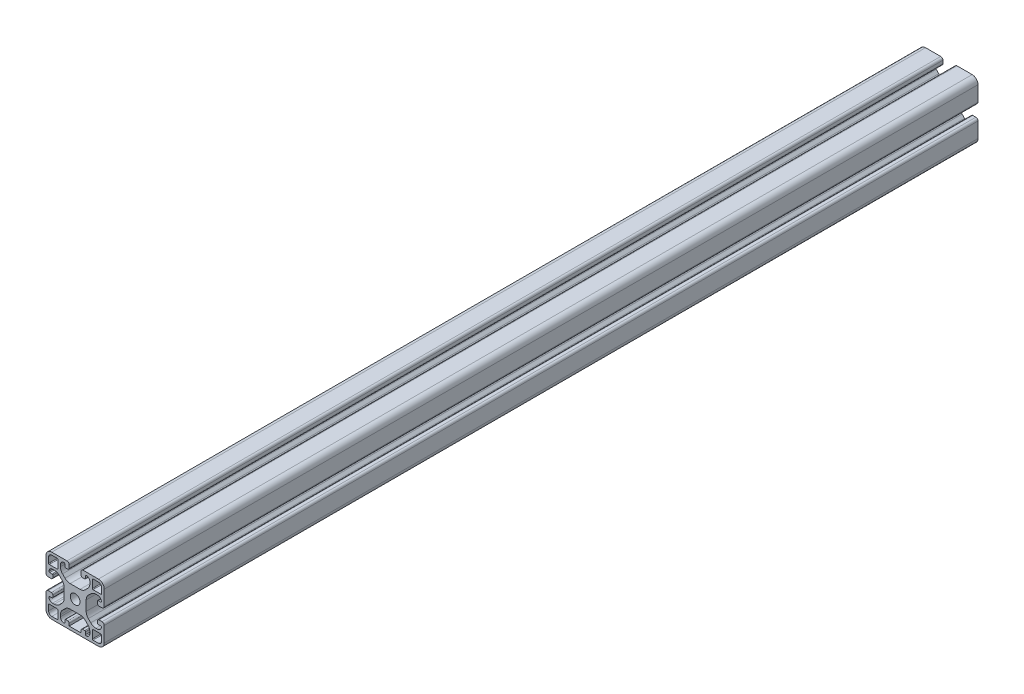
from build123d import *

# Parameters (mm, degrees)
SKIZZE1_R                       = 3.35
AUFSATZ_LINEAR_AUSTRAGEN1_DEPTH = 600


with BuildPart() as part:
    # Skizze1 → Aufsatz-Linear austragen1 (new body)
    with BuildSketch(Plane.XY.offset(1000)):
        with BuildLine():
            Line((5.899999985, 34.292388165), (5.899999985, 35.500000003))
            ThreePointArc((5.899999985, 35.500000003), (6.632233037, 37.267766961), (8.399999999, 38.000000003))
            ThreePointArc((8.399999999, 38.000000003), (8.753553388, 37.853553393), (8.899999996, 37.500000003))
            Line((8.899999996, 37.500000003), (8.899999996, 35.850000004))
            ThreePointArc((8.899999996, 35.850000004), (9.046446605, 35.496446613), (9.399999996, 35.350000004))
            Line((9.399999996, 35.350000004), (10.899999947, 35.350000004))
            ThreePointArc((10.899999947, 35.350000004), (11.607106728, 35.642893223), (11.899999947, 36.350000004))
            Line((11.899999947, 36.350000004), (11.899999947, 38.500000016))
            ThreePointArc((11.899999947, 38.500000016), (11.460660119, 39.560660188), (10.399999947, 40.000000016))
            Line((10.399999947, 40.000000016), (5.2e-08, 40.000000016))
            ThreePointArc((5.2e-08, 40.000000016), (-2.828427117, 38.828427123), (-4.000000011, 35.999999954))
            Line((-4.000000011, 35.999999954), (-4.000000011, 25.599999996))
            ThreePointArc((-4.000000011, 25.599999996), (-3.560660183, 24.539339825), (-2.500000012, 24.099999997))
            Line((-2.500000012, 24.099999997), (-0.350000011, 24.099999997))
            ThreePointArc((-0.350000011, 24.099999997), (0.35710677, 24.392893216), (0.649999989, 25.099999997))
            Line((0.649999989, 25.099999997), (0.649999989, 26.599999997))
            ThreePointArc((0.649999989, 26.599999997), (0.50355338, 26.953553387), (0.149999989, 27.099999997))
            Line((0.149999989, 27.099999997), (-1.500000011, 27.099999997))
            ThreePointArc((-1.500000011, 27.099999997), (-1.853553401, 27.246446605), (-2.000000011, 27.599999993))
            ThreePointArc((-2.000000011, 27.599999993), (-1.26776697, 29.367766957), (0.499999989, 30.10000001))
            Line((0.499999989, 30.10000001), (1.707611833, 30.10000001))
            ThreePointArc((1.707611833, 30.10000001), (3.621028995, 29.719397673), (5.243145739, 28.635533916))
            Line((5.243145739, 28.635533916), (6.935533894, 26.943145761))
            ThreePointArc((6.935533894, 26.943145761), (8.01939765, 25.321029017), (8.399999988, 23.407611855))
            Line((8.399999988, 23.407611855), (8.399999988, 16.592388122))
            ThreePointArc((8.399999988, 16.592388122), (8.01939765, 14.678970961), (6.935533894, 13.056854217))
            Line((6.935533894, 13.056854217), (5.243145737, 11.36446606))
            ThreePointArc((5.243145737, 11.36446606), (3.621028993, 10.280602303), (1.707611831, 9.899999966))
            Line((1.707611831, 9.899999966), (0.49999999, 9.899999966))
            ThreePointArc((0.49999999, 9.899999966), (-1.267766968, 10.632233018), (-2.00000001, 12.399999979))
            ThreePointArc((-2.00000001, 12.399999979), (-1.8535534, 12.753553368), (-1.50000001, 12.899999977))
            Line((-1.50000001, 12.899999977), (0.149999989, 12.899999977))
            ThreePointArc((0.149999989, 12.899999977), (0.50355338, 13.046446586), (0.649999989, 13.399999977))
            Line((0.649999989, 13.399999977), (0.649999989, 14.899999976))
            ThreePointArc((0.649999989, 14.899999976), (0.35710677, 15.607106757), (-0.350000011, 15.899999976))
            Line((-0.350000011, 15.899999976), (-2.50000001, 15.899999976))
            ThreePointArc((-2.50000001, 15.899999976), (-3.560660182, 15.460660148), (-4.000000011, 14.399999976))
            Line((-4.000000011, 14.399999976), (-4.000000011, 4.000000069))
            ThreePointArc((-4.000000011, 4.000000069), (-2.828427121, 1.171572909), (4e-08, 1.9e-08))
            Line((4e-08, 1.9e-08), (31.999999925, 1.9e-08))
            ThreePointArc((31.999999925, 1.9e-08), (34.828427086, 1.171572909), (35.999999976, 4.00000007))
            Line((35.999999976, 4.00000007), (35.999999976, 14.399999977))
            ThreePointArc((35.999999976, 14.399999977), (35.560660149, 15.460660148), (34.499999978, 15.899999976))
            Line((34.499999978, 15.899999976), (32.349999991, 15.899999976))
            ThreePointArc((32.349999991, 15.899999976), (31.642893209, 15.607106757), (31.34999999, 14.899999976))
            Line((31.34999999, 14.899999976), (31.34999999, 13.399999977))
            ThreePointArc((31.34999999, 13.399999977), (31.4964466, 13.046446586), (31.84999999, 12.899999977))
            Line((31.84999999, 12.899999977), (33.499999991, 12.899999977))
            ThreePointArc((33.499999991, 12.899999977), (33.853553381, 12.753553368), (33.999999991, 12.399999979))
            ThreePointArc((33.999999991, 12.399999979), (33.267766949, 10.632233018), (31.499999991, 9.899999966))
            Line((31.499999991, 9.899999966), (30.292388185, 9.899999966))
            ThreePointArc((30.292388185, 9.899999966), (28.378971023, 10.280602303), (26.756854279, 11.36446606))
            Line((26.756854279, 11.36446606), (25.064466082, 13.056854257))
            ThreePointArc((25.064466082, 13.056854257), (23.980602325, 14.678971001), (23.599999988, 16.592388163))
            Line((23.599999988, 16.592388163), (23.599999988, 23.407611842))
            ThreePointArc((23.599999988, 23.407611842), (23.980602325, 25.321029004), (25.064466082, 26.943145747))
            Line((25.064466082, 26.943145747), (26.75685425, 28.635533916))
            ThreePointArc((26.75685425, 28.635533916), (28.378970995, 29.719397673), (30.292388156, 30.10000001))
            Line((30.292388156, 30.10000001), (31.499999989, 30.10000001))
            ThreePointArc((31.499999989, 30.10000001), (33.267766948, 29.367766957), (33.999999989, 27.599999993))
            ThreePointArc((33.999999989, 27.599999993), (33.853553379, 27.246446605), (33.499999989, 27.099999997))
            Line((33.499999989, 27.099999997), (31.84999999, 27.099999997))
            ThreePointArc((31.84999999, 27.099999997), (31.4964466, 26.953553387), (31.34999999, 26.599999997))
            Line((31.34999999, 26.599999997), (31.34999999, 25.099999997))
            ThreePointArc((31.34999999, 25.099999997), (31.642893209, 24.392893216), (32.34999999, 24.099999997))
            Line((32.34999999, 24.099999997), (34.499999976, 24.099999997))
            ThreePointArc((34.499999976, 24.099999997), (35.560660148, 24.539339825), (35.999999976, 25.599999997))
            Line((35.999999976, 25.599999997), (35.999999976, 35.999999953))
            ThreePointArc((35.999999976, 35.999999953), (34.828427083, 38.828427123), (31.999999914, 40.000000016))
            Line((31.999999914, 40.000000016), (21.600000015, 40.000000016))
            ThreePointArc((21.600000015, 40.000000016), (20.539339844, 39.560660188), (20.100000016, 38.500000017))
            Line((20.100000016, 38.500000017), (20.100000016, 36.350000004))
            ThreePointArc((20.100000016, 36.350000004), (20.392893235, 35.642893223), (21.100000017, 35.350000004))
            Line((21.100000017, 35.350000004), (22.600000014, 35.350000004))
            ThreePointArc((22.600000014, 35.350000004), (22.953553405, 35.496446613), (23.100000014, 35.850000004))
            Line((23.100000014, 35.850000004), (23.100000014, 37.500000007))
            ThreePointArc((23.100000014, 37.500000007), (23.246446625, 37.8535534), (23.600000019, 38.000000007))
            ThreePointArc((23.600000019, 38.000000007), (25.367766955, 37.267766951), (26.099999992, 35.500000007))
            Line((26.099999992, 35.500000007), (26.099999992, 34.292388127))
            ThreePointArc((26.099999992, 34.292388127), (25.719397655, 32.378970966), (24.635533898, 30.756854221))
            Line((24.635533898, 30.756854221), (22.943145779, 29.064466103))
            ThreePointArc((22.943145779, 29.064466103), (21.321029035, 27.980602346), (19.407611873, 27.600000009))
            Line((19.407611873, 27.600000009), (12.592388142, 27.600000009))
            ThreePointArc((12.592388142, 27.600000009), (10.678970981, 27.980602346), (9.056854237, 29.064466102))
            Line((9.056854237, 29.064466102), (7.36446608, 30.75685426))
            ThreePointArc((7.36446608, 30.75685426), (6.280602323, 32.378971004), (5.899999985, 34.292388165))
        make_face()
        with Locations((15.999999985, 20)):
            Circle(SKIZZE1_R, mode=Mode.SUBTRACT)
        with BuildLine():
            Line((27.799999996, 32.299999708), (27.799999996, 37.700000083))
            ThreePointArc((27.799999996, 37.700000083), (27.946446591, 38.053553439), (28.299999947, 38.200000034))
            Line((28.299999947, 38.200000034), (31.999999914, 38.200000034))
            ThreePointArc((31.999999914, 38.200000034), (33.555634889, 37.555634929), (34.199999994, 35.999999953))
            Line((34.199999994, 35.999999953), (34.199999994, 32.300000046))
            ThreePointArc((34.199999994, 32.300000046), (34.053553382, 31.946446648), (33.699999983, 31.800000035))
            Line((33.699999983, 31.800000035), (28.299999669, 31.800000035))
            ThreePointArc((28.299999669, 31.800000035), (27.94644651, 31.946446549), (27.799999996, 32.299999708))
        make_face(mode=Mode.SUBTRACT)
        with BuildLine():
            Line((28.299999669, 8.199999998), (33.700000043, 8.199999998))
            ThreePointArc((33.700000043, 8.199999998), (34.053553399, 8.053553402), (34.199999994, 7.700000046))
            Line((34.199999994, 7.700000046), (34.199999994, 4.00000007))
            ThreePointArc((34.199999994, 4.00000007), (33.555634893, 2.444365103), (31.999999925, 1.800000001))
            Line((31.999999925, 1.800000001), (28.300000007, 1.800000001))
            ThreePointArc((28.300000007, 1.800000001), (27.946446609, 1.946446613), (27.799999996, 2.300000012))
            Line((27.799999996, 2.300000012), (27.799999996, 7.700000324))
            ThreePointArc((27.799999996, 7.700000324), (27.94644651, 8.053553484), (28.299999669, 8.199999998))
        make_face(mode=Mode.SUBTRACT)
        with BuildLine():
            Line((3.700000285, 31.800000035), (-1.700000077, 31.800000035))
            ThreePointArc((-1.700000077, 31.800000035), (-2.053553433, 31.94644663), (-2.200000029, 32.299999986))
            Line((-2.200000029, 32.299999986), (-2.200000029, 35.999999954))
            ThreePointArc((-2.200000029, 35.999999954), (-1.555634924, 37.555634929), (5.2e-08, 38.200000034))
            Line((5.2e-08, 38.200000034), (3.699999947, 38.200000034))
            ThreePointArc((3.699999947, 38.200000034), (4.053553346, 38.053553422), (4.199999959, 37.700000023))
            Line((4.199999959, 37.700000023), (4.199999959, 32.299999708))
            ThreePointArc((4.199999959, 32.299999708), (4.053553445, 31.946446549), (3.700000285, 31.800000035))
        make_face(mode=Mode.SUBTRACT)
        with BuildLine():
            Line((4.199999959, 7.700000324), (4.199999959, 2.299999952))
            ThreePointArc((4.199999959, 2.299999952), (4.053553363, 1.946446596), (3.700000007, 1.800000001))
            Line((3.700000007, 1.800000001), (4e-08, 1.800000001))
            ThreePointArc((4e-08, 1.800000001), (-1.555634927, 2.444365102), (-2.200000029, 4.000000069))
            Line((-2.200000029, 4.000000069), (-2.200000029, 7.699999986))
            ThreePointArc((-2.200000029, 7.699999986), (-2.053553416, 8.053553385), (-1.700000017, 8.199999998))
            Line((-1.700000017, 8.199999998), (3.700000285, 8.199999998))
            ThreePointArc((3.700000285, 8.199999998), (4.053553445, 8.053553484), (4.199999959, 7.700000324))
        make_face(mode=Mode.SUBTRACT)
        with BuildLine():
            Line((20.100000016, 2.000000008), (11.899999947, 2.000000008))
            Line((11.899999947, 2.000000008), (11.899999947, 3.649999992))
            ThreePointArc((11.899999947, 3.649999992), (11.607106728, 4.357106773), (10.899999947, 4.649999992))
            Line((10.899999947, 4.649999992), (9.399999996, 4.649999992))
            ThreePointArc((9.399999996, 4.649999992), (9.046446606, 4.503553382), (8.899999996, 4.149999992))
            Line((8.899999996, 4.149999992), (8.899999996, 2.499999991))
            ThreePointArc((8.899999996, 2.499999991), (8.753553389, 2.146446604), (8.400000003, 1.999999994))
            ThreePointArc((8.400000003, 1.999999994), (6.632233039, 2.732233035), (5.899999985, 4.499999994))
            Line((5.899999985, 4.499999994), (5.899999985, 5.707611838))
            ThreePointArc((5.899999985, 5.707611838), (6.280602323, 7.621029001), (7.36446608, 9.243145746))
            Line((7.36446608, 9.243145746), (9.056854238, 10.935533903))
            ThreePointArc((9.056854238, 10.935533903), (10.678970982, 12.01939766), (12.592388143, 12.399999997))
            Line((12.592388143, 12.399999997), (19.407611847, 12.399999997))
            ThreePointArc((19.407611847, 12.399999997), (21.321029008, 12.01939766), (22.943145752, 10.935533904))
            Line((22.943145752, 10.935533904), (24.635533898, 9.243145757))
            ThreePointArc((24.635533898, 9.243145757), (25.719397655, 7.621029013), (26.099999992, 5.707611851))
            Line((26.099999992, 5.707611851), (26.099999992, 4.499999993))
            ThreePointArc((26.099999992, 4.499999993), (25.367766954, 2.73223305), (23.600000019, 1.999999995))
            ThreePointArc((23.600000019, 1.999999995), (23.246446625, 2.146446603), (23.100000014, 2.499999995))
            Line((23.100000014, 2.499999995), (23.100000014, 4.149999994))
            ThreePointArc((23.100000014, 4.149999994), (22.953553405, 4.503553383), (22.600000016, 4.649999992))
            Line((22.600000016, 4.649999992), (21.100000017, 4.649999992))
            ThreePointArc((21.100000017, 4.649999992), (20.392893235, 4.357106773), (20.100000016, 3.649999992))
            Line((20.100000016, 3.649999992), (20.100000016, 2.000000008))
        make_face(mode=Mode.SUBTRACT)
    extrude(amount=-AUFSATZ_LINEAR_AUSTRAGEN1_DEPTH)


solid = part.part
